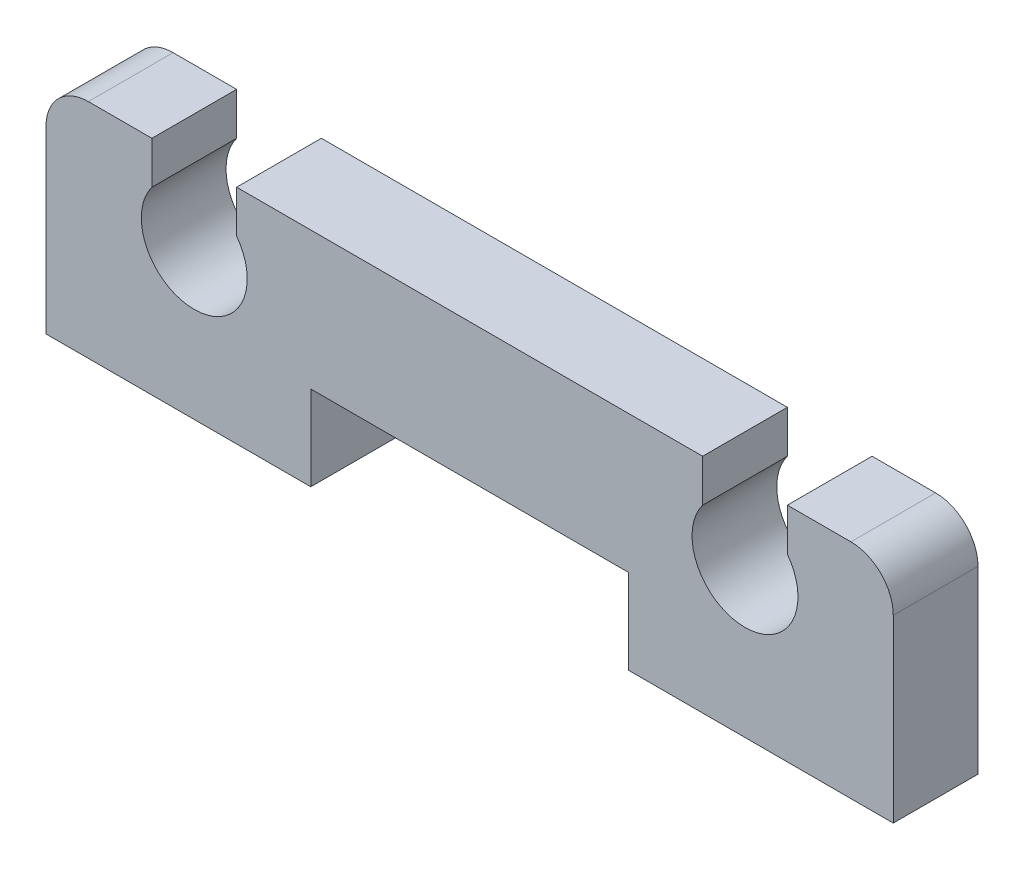
from build123d import *

# Parameters (mm, degrees)
TUBE_PLATE_BODY_DEPTH   = 2
TUBE_PLATE_CONTOURING_R = 1


with BuildPart() as part:
    # Sketch1 → Tube Plate Body (new body)
    with BuildSketch(Plane.XY):
        with BuildLine():
            Line((-10, 0), (-10, 5.25))
            Line((-10, 5.25), (-7.5, 5.25))
            Line((-7.5, 5.25), (-7.5, 4.25))
            ThreePointArc((-7.5, 4.25), (-6.5, 2.25), (-5.5, 4.25))
            Line((-5.5, 4.25), (-5.5, 5.25))
            Line((-5.5, 5.25), (5.5, 5.25))
            Line((5.5, 5.25), (5.5, 4.25))
            ThreePointArc((5.5, 4.25), (6.5, 2.25), (7.5, 4.25))
            Line((7.5, 4.25), (7.5, 5.25))
            Line((7.5, 5.25), (10, 5.25))
            Line((10, 5.25), (10, 0))
            Line((10, 0), (3.75, 0))
            Line((3.75, 0), (3.75, 2))
            Line((3.75, 2), (-3.75, 2))
            Line((-3.75, 2), (-3.75, 0))
            Line((-3.75, 0), (-10, 0))
        make_face()
    extrude(amount=TUBE_PLATE_BODY_DEPTH)

    # Tube Plate Contouring
    tube_plate_contouring_edges = [part.edges().sort_by_distance(p)[0] for p in [
        (-10, 5.25, 1),
        (10, 5.25, 1),
    ]]
    fillet(tube_plate_contouring_edges, radius=TUBE_PLATE_CONTOURING_R)


solid = part.part
